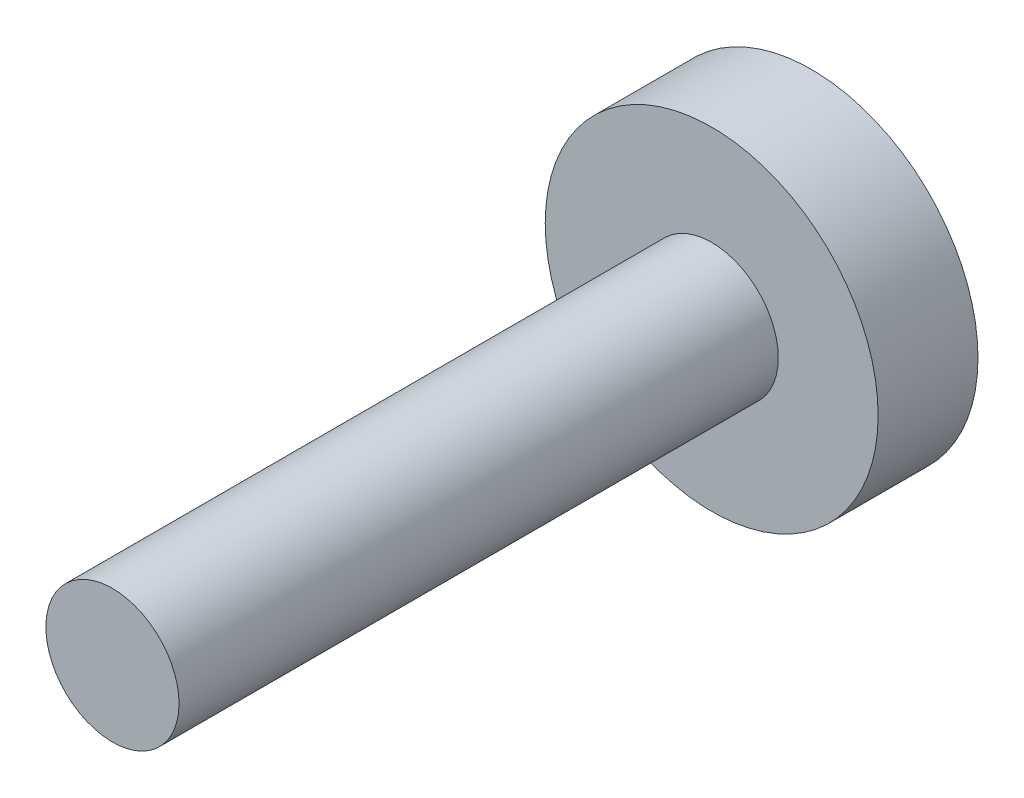
from build123d import *

# Parameters (mm, degrees)
SKETCH1_R           = 5
BOSS_EXTRUDE1_DEPTH = 3
SKETCH2_R           = 2
BOSS_EXTRUDE2_DEPTH = 18


with BuildPart() as part:
    # Sketch1 → Boss-Extrude1 (new body)
    with BuildSketch(Plane.XY):
        Circle(SKETCH1_R)
    extrude(amount=BOSS_EXTRUDE1_DEPTH)

    # Sketch2 → Boss-Extrude2 (add)
    with BuildSketch(Plane.XY.offset(3)):
        Circle(SKETCH2_R)
    extrude(amount=BOSS_EXTRUDE2_DEPTH)


solid = part.part
